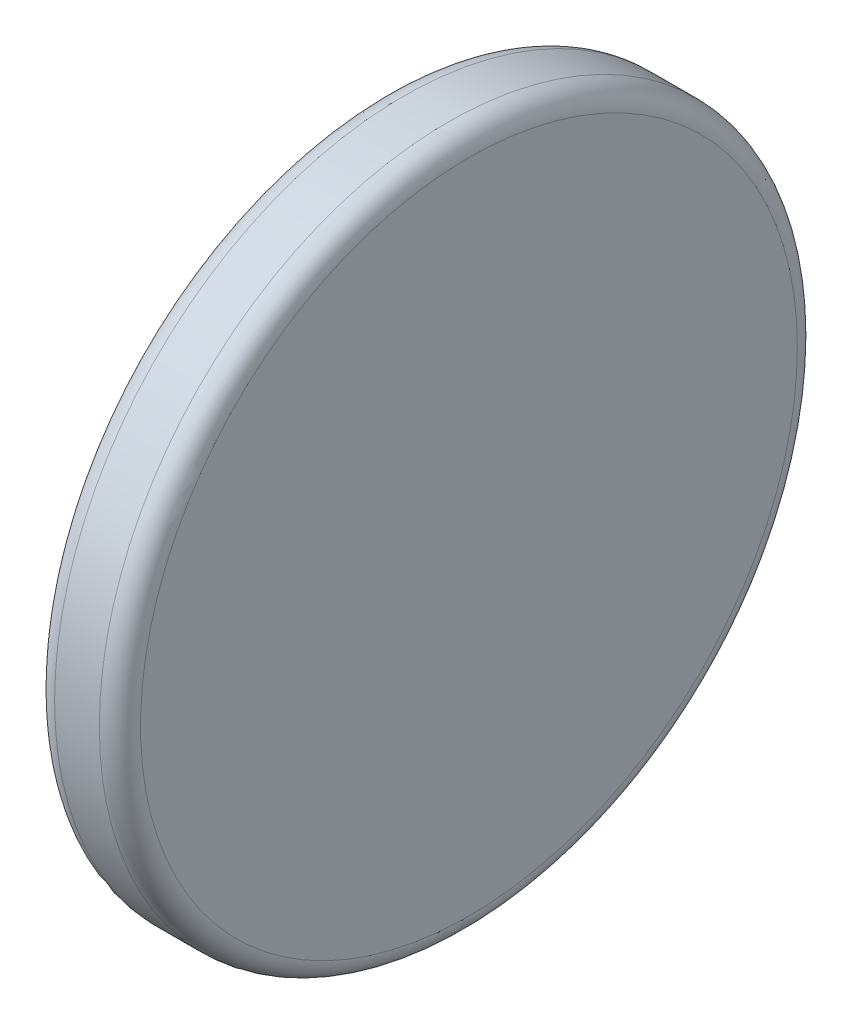
from build123d import *

# Parameters (mm, degrees)
SKETCH1_R           = 203.2
BOSS_EXTRUDE1_DEPTH = 25
FILLET1_R           = 12


with BuildPart() as part:
    # Sketch1 → Boss-Extrude1 (new body, symmetric)
    with BuildSketch(Plane(origin=(0, 0, 0), x_dir=(0, 0, -1), z_dir=(1, 0, 0))):
        Circle(SKETCH1_R)
    extrude(amount=BOSS_EXTRUDE1_DEPTH, both=True)

    # Fillet1
    fillet1_edges = [part.edges().sort_by_distance(p)[0] for p in [
        (-25, 0, 203.2),
        (25, 0, 203.2),
    ]]
    fillet(fillet1_edges, radius=FILLET1_R)


solid = part.part
